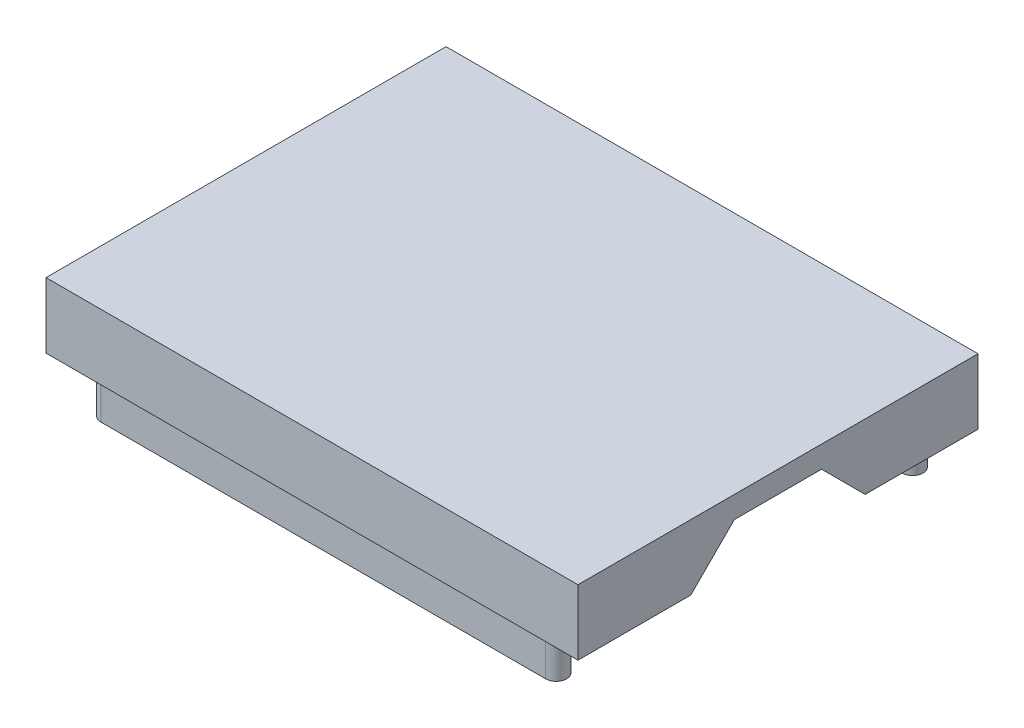
from build123d import *

# Parameters (mm, degrees)
SKETCH1_W           = 30.988
SKETCH1_H           = 23.3045
BOSS_EXTRUDE1_DEPTH = 3.81
CUT_EXTRUDE1_DEPTH  = 29.718
BOSS_EXTRUDE2_DEPTH = 2.54
SKETCH4_W           = 25.908
SKETCH4_H           = 18.2245
CUT_EXTRUDE2_DEPTH  = 2.54


with BuildPart() as part:
    # Sketch1 → Boss-Extrude1 (new body)
    with BuildSketch(Plane(origin=(0, 0, 0), x_dir=(1, 0, 0), z_dir=(0, 1, 0))):
        with Locations((15.494, 11.65225)):
            Rectangle(SKETCH1_W, SKETCH1_H)
    extrude(amount=BOSS_EXTRUDE1_DEPTH)

    # Sketch2 → Cut-Extrude1 (cut)
    with BuildSketch(Plane(origin=(30.988, 0, 0), x_dir=(0, 0, -1), z_dir=(1, 0, 0))):
        Polygon((6.57225, 0), (9.11225, 2.54), (14.19225, 2.54), (16.73225, 0), align=None)
    extrude(amount=-CUT_EXTRUDE1_DEPTH, mode=Mode.SUBTRACT)

    # Sketch3 → Boss-Extrude2 (add)
    with BuildSketch(Plane.XZ):
        with BuildLine():
            Line((2.54, -0.6604), (28.448, -0.6604))
            ThreePointArc((28.448, -0.6604), (29.0576, -1.27), (28.448, -1.8796))
            Line((28.448, -1.8796), (2.54, -1.8796))
            ThreePointArc((2.54, -1.8796), (1.9304, -1.27), (2.54, -0.6604))
        make_face()
        with BuildLine():
            Line((2.54, -21.4249), (28.448, -21.4249))
            ThreePointArc((28.448, -21.4249), (29.0576, -22.0345), (28.448, -22.6441))
            Line((28.448, -22.6441), (2.54, -22.6441))
            ThreePointArc((2.54, -22.6441), (1.9304, -22.0345), (2.54, -21.4249))
        make_face()
    extrude(amount=BOSS_EXTRUDE2_DEPTH)

    # Sketch4 → Cut-Extrude2 (cut)
    with BuildSketch(Plane.XZ):
        with Locations((15.494, -11.65225)):
            Rectangle(SKETCH4_W, SKETCH4_H)
    extrude(amount=-CUT_EXTRUDE2_DEPTH, mode=Mode.SUBTRACT)


solid = part.part
